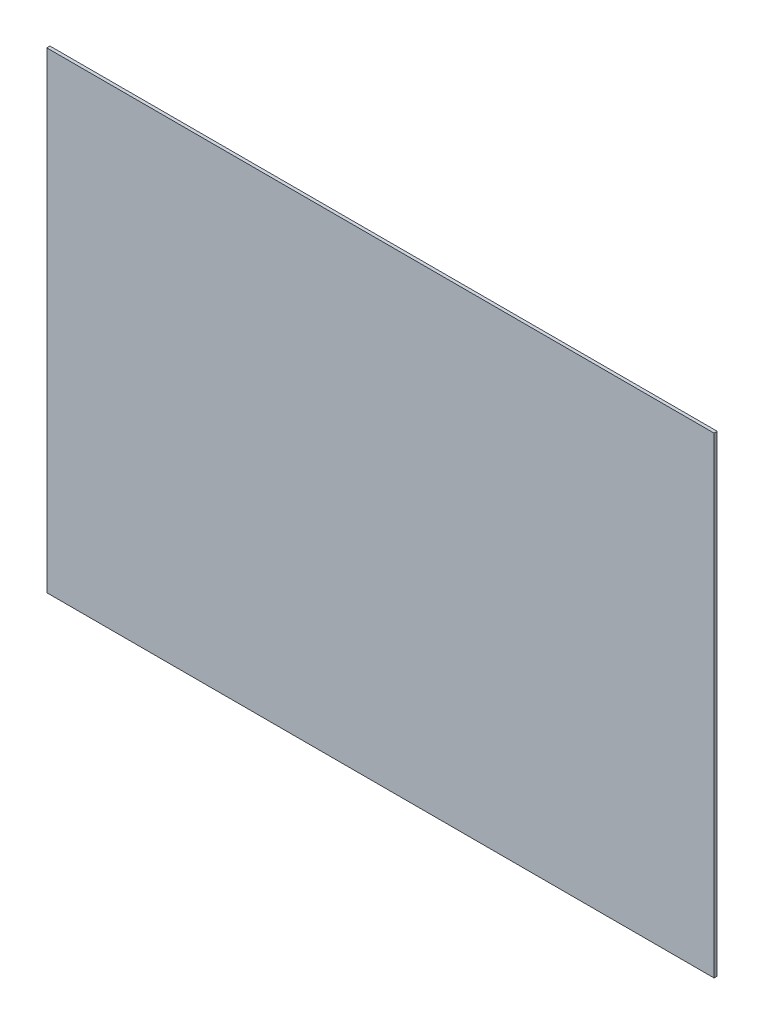
from build123d import *

# Parameters (mm, degrees)
SKETCH1_W           = 420
SKETCH1_H           = 297
BOSS_EXTRUDE1_DEPTH = 2


with BuildPart() as part:
    # Sketch1 → Boss-Extrude1 (new body)
    with BuildSketch(Plane.XY):
        with Locations((210, 148.5)):
            Rectangle(SKETCH1_W, SKETCH1_H)
    extrude(amount=BOSS_EXTRUDE1_DEPTH)


solid = part.part
